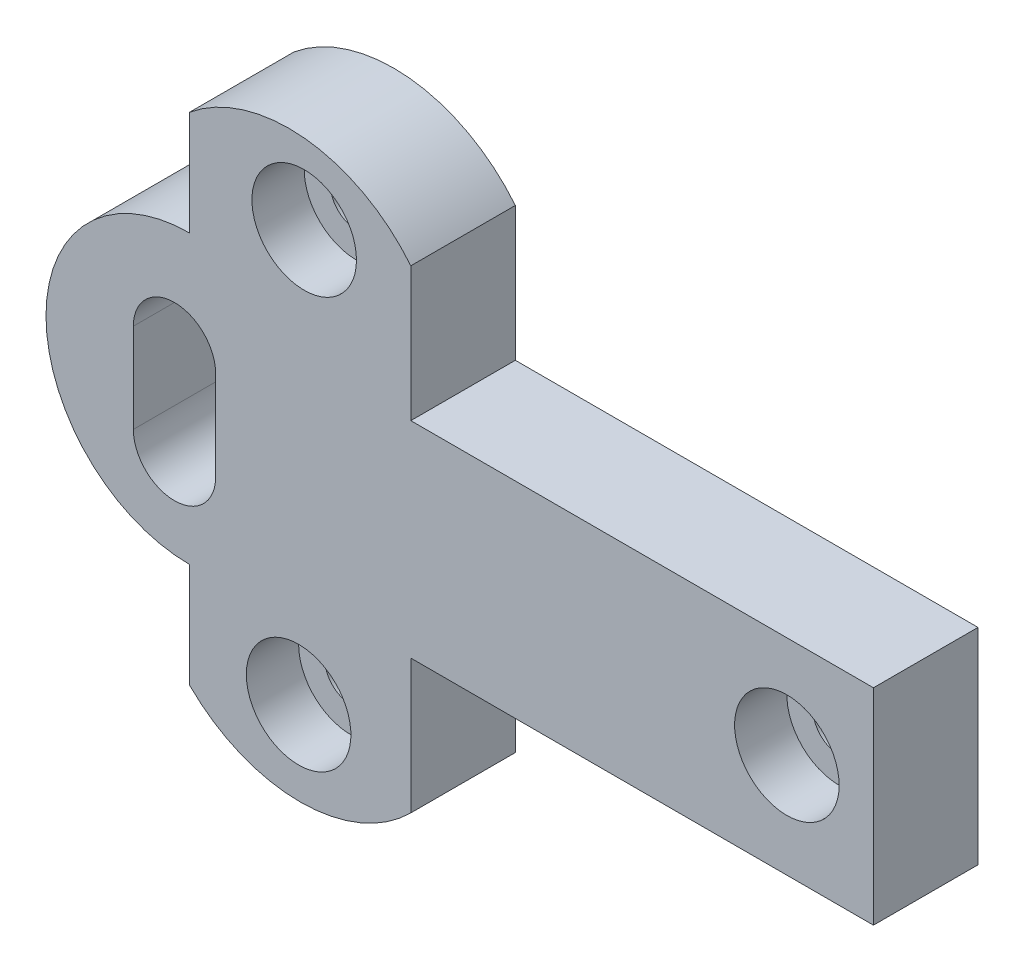
from build123d import *

# Parameters (mm, degrees)
BOSS_EXTRUDE1_DEPTH = 20
SKETCH2_R           = 10
CUT_EXTRUDE1_DEPTH  = 10
CUT_EXTRUDE2_DEPTH  = 20
SKETCH4_R           = 5
CUT_EXTRUDE3_DEPTH  = 20


with BuildPart() as part:
    # Sketch1 → Boss-Extrude1 (new body)
    with BuildSketch(Plane.XY):
        with BuildLine():
            Line((46.177047915, 17.530175597), (-42.328960588, 17.530175597))
            Line((-42.328960588, 17.530175597), (-42.328960588, 43.184091105))
            ThreePointArc((-42.328960588, 43.184091105), (-62.602792244, 54.153197241), (-84.660607586, 47.459743594))
            Line((-84.660607586, 47.459743594), (-84.660607586, 27.459743594))
            ThreePointArc((-84.660607586, 27.459743594), (-112.119008023, -0.001343253), (-84.657921177, -27.45974369))
            Line((-84.657921177, -27.45974369), (-84.657921177, -47.45974369))
            ThreePointArc((-84.657921177, -47.45974369), (-63.493440882, -56.226358468), (-42.328960588, -47.45974369))
            Line((-42.328960588, -47.45974369), (-42.328960588, -21.805828182))
            Line((-42.328960588, -21.805828182), (46.177047915, -21.805828182))
            Line((46.177047915, -21.805828182), (46.177047915, 17.530175597))
        make_face()
    extrude(amount=BOSS_EXTRUDE1_DEPTH)

    # Sketch2 → Cut-Extrude1 (cut)
    with BuildSketch(Plane.XY.offset(20)):
        with Locations((29.612265592, -1.914255488)):
            Circle(SKETCH2_R)
        with Locations((-62.725631092, 38.929575976)):
            Circle(SKETCH2_R)
        with Locations((-63.794313785, -40.25113932)):
            Circle(SKETCH2_R)
    extrude(amount=-CUT_EXTRUDE1_DEPTH, mode=Mode.SUBTRACT)

    # Sketch3 → Cut-Extrude2 (cut)
    with BuildSketch(Plane.XY.offset(20)):
        with BuildLine():
            Line((-95.412007987, -10.461867625), (-95.412007987, 6.633356649))
            ThreePointArc((-95.412007987, 6.633356649), (-87.536563025, 14.508801611), (-79.661118062, 6.633356649))
            Line((-79.661118062, 6.633356649), (-79.661118062, -10.461867625))
            ThreePointArc((-79.661118062, -10.461867625), (-87.536563025, -18.337312588), (-95.412007987, -10.461867625))
        make_face()
    extrude(amount=-CUT_EXTRUDE2_DEPTH, mode=Mode.SUBTRACT)

    # Sketch4 → Cut-Extrude3 (cut)
    with BuildSketch(Plane.XY.offset(20)):
        with Locations((-62.725631092, 38.929575976)):
            Circle(SKETCH4_R)
        with Locations((-63.794313785, -40.25113932)):
            Circle(SKETCH4_R)
        with Locations((29.612265592, -1.914255488)):
            Circle(SKETCH4_R)
    extrude(amount=-CUT_EXTRUDE3_DEPTH, mode=Mode.SUBTRACT)


solid = part.part
